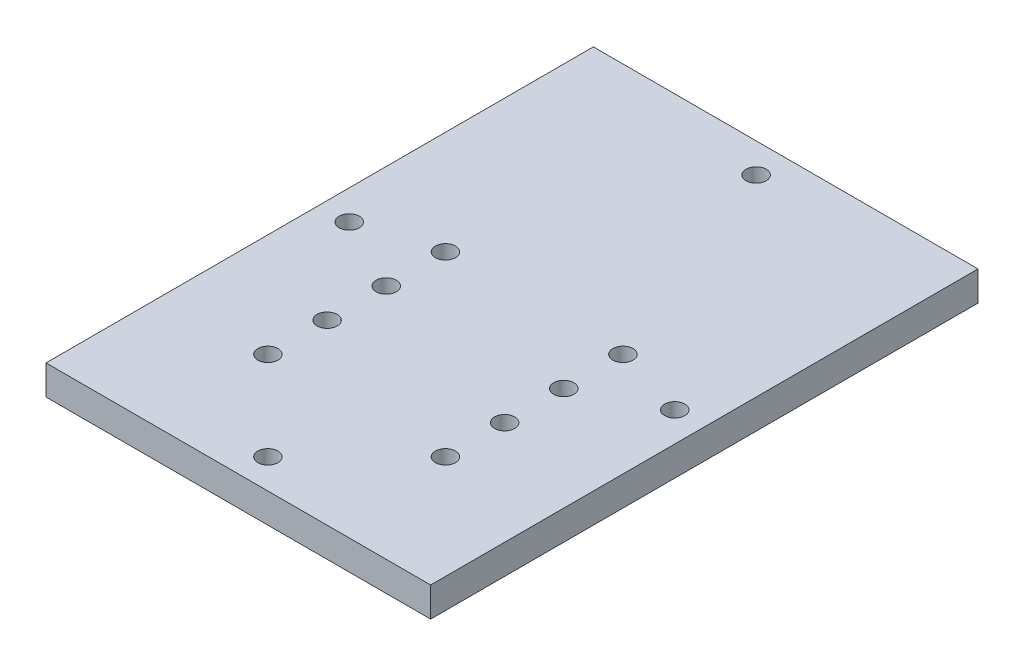
from build123d import *

# Parameters (mm, degrees)
SKETCH1_W           = 330.2
SKETCH1_H           = 469.9
SKETCH1_R           = 8.6487
BOSS_EXTRUDE1_DEPTH = 25.4


with BuildPart() as part:
    # Sketch1 → Boss-Extrude1 (new body)
    with BuildSketch(Plane(origin=(0, 0, 0), x_dir=(1, 0, 0), z_dir=(0, 1, 0))):
        with Locations((-165.1, 234.95)):
            Rectangle(SKETCH1_W, SKETCH1_H)
        with Locations((-165.1, 444.5)):
            Circle(SKETCH1_R, mode=Mode.SUBTRACT)
        with Locations((-25.4, 234.95)):
            Circle(SKETCH1_R, mode=Mode.SUBTRACT)
        with Locations((-165.1, 25.4)):
            Circle(SKETCH1_R, mode=Mode.SUBTRACT)
        with Locations((-304.8, 234.95)):
            Circle(SKETCH1_R, mode=Mode.SUBTRACT)
        with Locations((-88.9, 101.6)):
            Circle(SKETCH1_R, mode=Mode.SUBTRACT)
        with Locations((-88.9, 152.4)):
            Circle(SKETCH1_R, mode=Mode.SUBTRACT)
        with Locations((-88.9, 203.2)):
            Circle(SKETCH1_R, mode=Mode.SUBTRACT)
        with Locations((-88.9, 254)):
            Circle(SKETCH1_R, mode=Mode.SUBTRACT)
        with Locations((-241.3, 101.6)):
            Circle(SKETCH1_R, mode=Mode.SUBTRACT)
        with Locations((-241.3, 152.4)):
            Circle(SKETCH1_R, mode=Mode.SUBTRACT)
        with Locations((-241.3, 203.2)):
            Circle(SKETCH1_R, mode=Mode.SUBTRACT)
        with Locations((-241.3, 254)):
            Circle(SKETCH1_R, mode=Mode.SUBTRACT)
    extrude(amount=BOSS_EXTRUDE1_DEPTH)


solid = part.part
